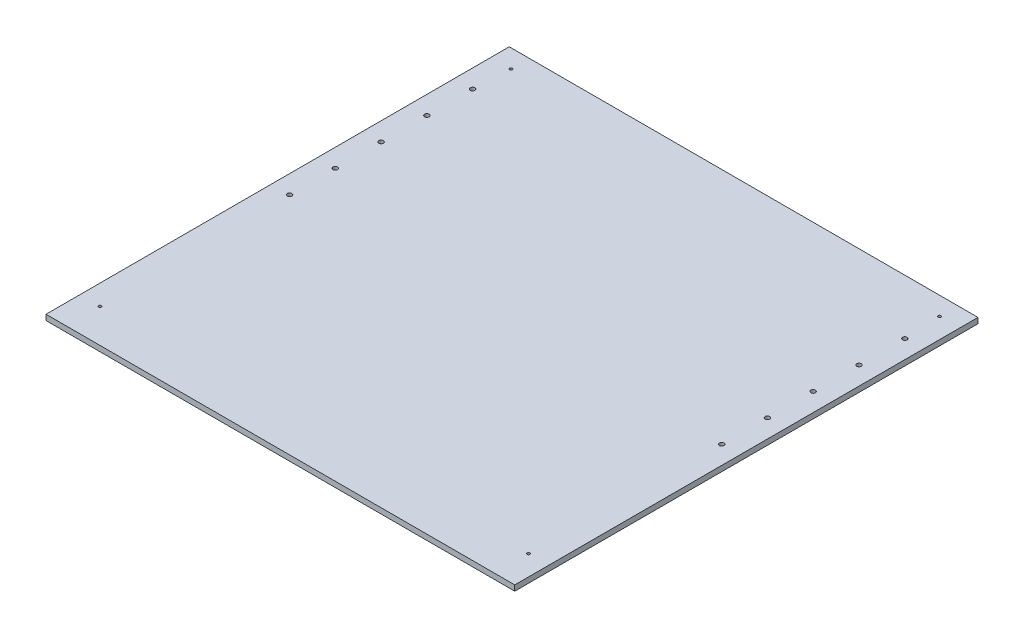
from build123d import *

# Parameters (mm, degrees)
SKETCH1_W           = 500
SKETCH1_H           = 500
SKETCH1_R           = 1.525
SKETCH1_R_2         = 1.5
BOSS_EXTRUDE1_DEPTH = 6
BOSS_EXTRUDE2_DEPTH = 6
SKETCH3_R           = 2.5
CUT_EXTRUDE1_DEPTH  = 7


with BuildPart() as part:
    # Sketch1 → Boss-Extrude1 (new body)
    with BuildSketch(Plane(origin=(0, 0, 0), x_dir=(1, 0, 0), z_dir=(0, 1, 0))):
        with Locations((250, -250)):
            Rectangle(SKETCH1_W, SKETCH1_H)
        with Locations((484, -20)):
            Circle(SKETCH1_R, mode=Mode.SUBTRACT)
        with Locations((16, -20)):
            Circle(SKETCH1_R_2, mode=Mode.SUBTRACT)
        with Locations((484, -469)):
            Circle(SKETCH1_R_2, mode=Mode.SUBTRACT)
        with Locations((16, -469)):
            Circle(SKETCH1_R_2, mode=Mode.SUBTRACT)
    extrude(amount=BOSS_EXTRUDE1_DEPTH)

    # Sketch2 → Boss-Extrude2 (add)
    with BuildSketch(Plane.XZ):
        Polygon((-6, 506), (-6, 0), (0, 0), (0, 500), (500, 500), (500, 0), (506, 0), (506, 506), align=None)
    extrude(amount=-BOSS_EXTRUDE2_DEPTH)

    # Sketch3 → Cut-Extrude1 (cut, through all)
    with BuildSketch(Plane.XZ):
        with Locations((14, 60)):
            Circle(SKETCH3_R)
        with Locations((14, 110)):
            Circle(SKETCH3_R)
        with Locations((14, 160)):
            Circle(SKETCH3_R)
        with Locations((14, 210)):
            Circle(SKETCH3_R)
        with Locations((14, 260)):
            Circle(SKETCH3_R)
        with Locations((486, 60)):
            Circle(SKETCH3_R)
        with Locations((486, 110)):
            Circle(SKETCH3_R)
        with Locations((486, 160)):
            Circle(SKETCH3_R)
        with Locations((486, 210)):
            Circle(SKETCH3_R)
        with Locations((486, 260)):
            Circle(SKETCH3_R)
    extrude(amount=-CUT_EXTRUDE1_DEPTH, mode=Mode.SUBTRACT)


solid = part.part
